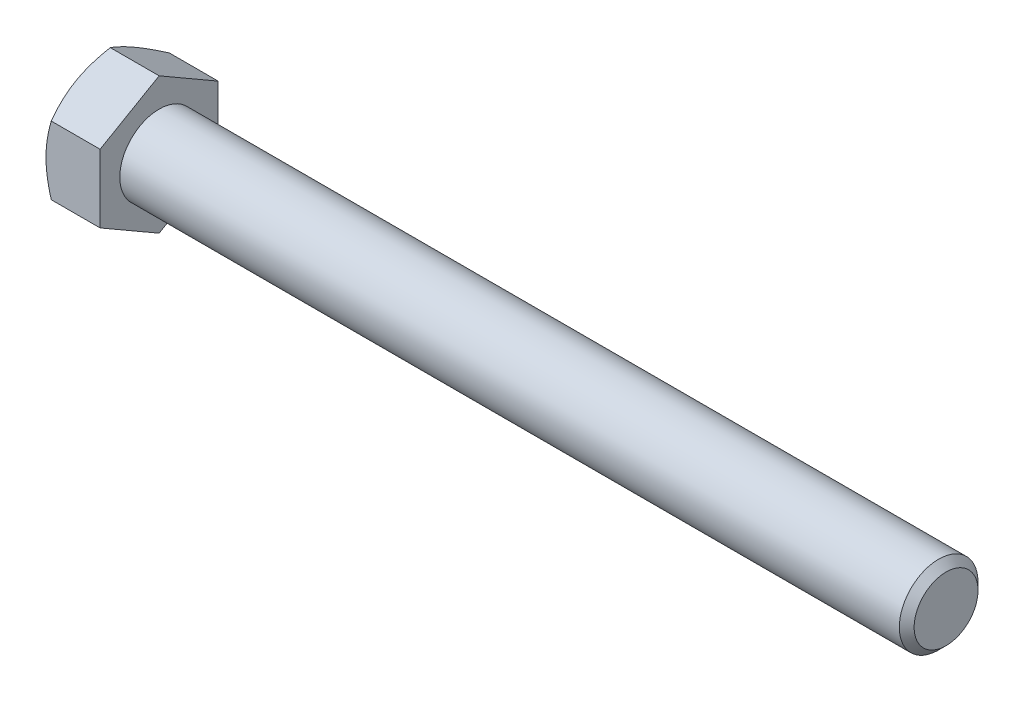
from build123d import *

# Parameters (mm, degrees)
SKETCH5_R           = 6.35
BOSS_EXTRUDE3_DEPTH = 127
CHAMFER1_SIZE       = 1.195753846
BOSS_EXTRUDE4_DEPTH = 8.73125
SKETCH8_OUTSIDE_W   = 522.464
SKETCH8_OUTSIDE_H   = 525.412
SKETCH8_OUTSIDE_R   = 9.525
CUT_EXTRUDE3_DEPTH  = 136.73125
CUT_EXTRUDE3_TAPER  = 60
CUT_EXTRUDE4_DEPTH  = 0.254
CIRPATTERN1_COUNT   = 3


with BuildPart() as part:
    # Sketch5 → Boss-Extrude3 (new body)
    with BuildSketch(Plane(origin=(67.865625, 0, 0), x_dir=(0, 0, -1), z_dir=(1, 0, 0))):
        Circle(SKETCH5_R)
    extrude(amount=-BOSS_EXTRUDE3_DEPTH)

    # Chamfer1
    chamfer1_edges = [part.edges().sort_by_distance(p)[0] for p in [
        (67.865625, 0, 6.35),
    ]]
    chamfer(chamfer1_edges, length=CHAMFER1_SIZE)

    # Sketch6 → Boss-Extrude4 (add)
    with BuildSketch(Plane.ZY.offset(59.134375)):
        Polygon((9.525, 5.499261314), (0, 10.998522628), (-9.525, 5.499261314), (-9.525, -5.499261314), (0, -10.998522628), (9.525, -5.499261314), align=None)
    extrude(amount=BOSS_EXTRUDE4_DEPTH)

    # Sketch8 outside → Cut-Extrude3 (cut, through all)
    with BuildSketch(Plane.ZY.offset(67.865625)):
        Rectangle(SKETCH8_OUTSIDE_W, SKETCH8_OUTSIDE_H)
        Circle(SKETCH8_OUTSIDE_R, mode=Mode.SUBTRACT)
    extrude(amount=-CUT_EXTRUDE3_DEPTH, taper=CUT_EXTRUDE3_TAPER, mode=Mode.SUBTRACT)

    # Sketch12 → Cut-Extrude4 (cut)
    with BuildSketch(Plane.ZY.offset(67.865625)):
        with BuildLine():
            Line((0.28575, 7.33425), (0.28575, 4.09575))
            ThreePointArc((0.28575, 4.09575), (0, 3.81), (-0.28575, 4.09575))
            Line((-0.28575, 4.09575), (-0.28575, 7.33425))
            ThreePointArc((-0.28575, 7.33425), (0, 7.62), (0.28575, 7.33425))
        make_face()
    cut_extrude4 = extrude(amount=-CUT_EXTRUDE4_DEPTH, mode=Mode.SUBTRACT)

    # CirPattern1: Cut-Extrude4 ×3 about axis
    cirpattern1_axis = Axis((0, 0, 0), (1, 0, 0))
    for i in range(1, CIRPATTERN1_COUNT):
        add(cut_extrude4.rotate(cirpattern1_axis, i * 360 / CIRPATTERN1_COUNT), mode=Mode.SUBTRACT)


solid = part.part
